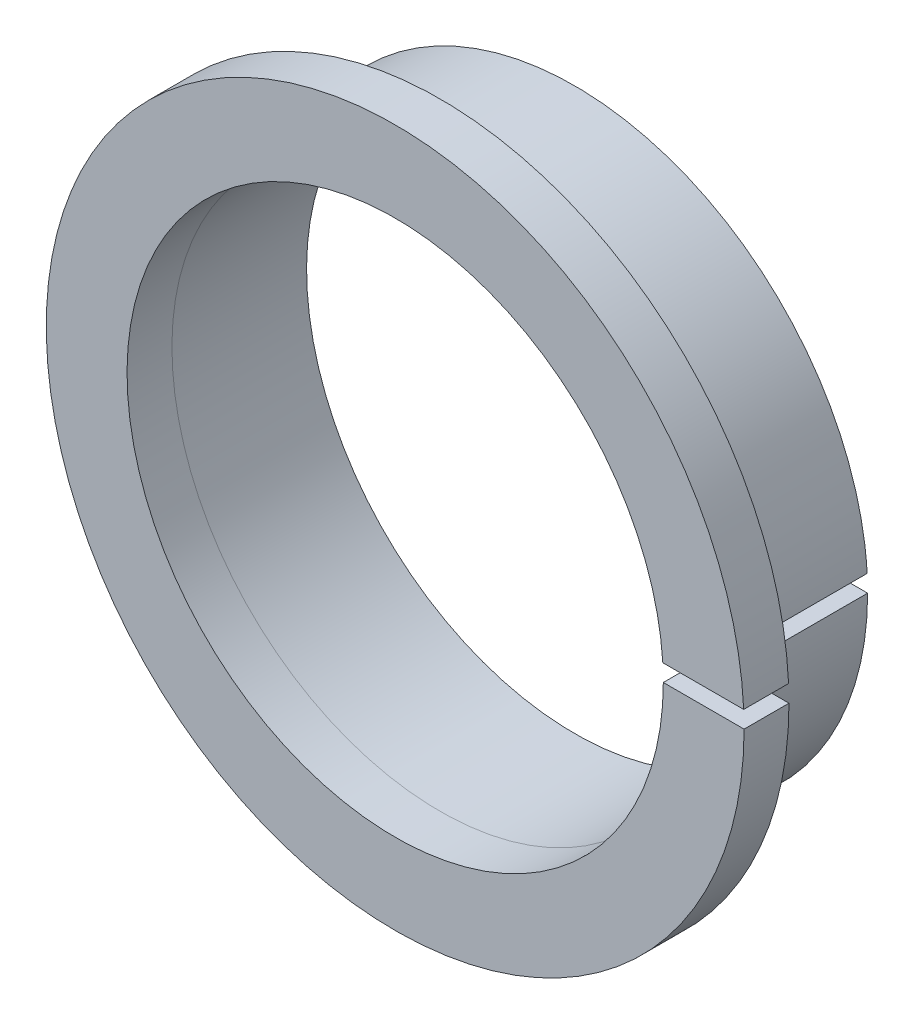
from build123d import *

# Parameters (mm, degrees)
BOSS_EXTRUDE1_DEPTH = 2
BOSS_EXTRUDE2_DEPTH = 6


with BuildPart() as part:
    # Sketch1 → Boss-Extrude1 (new body)
    with BuildSketch(Plane.XY):
        with BuildLine():
            Line((11.925831049, 0.750033398), (15.531084626, 0.75006687))
            ThreePointArc((15.531084626, 0.75006687), (-15.544679762, -0.375143285), (15.549186156, 0))
            Line((15.549186156, 0), (11.949393131, 0))
            ThreePointArc((11.949393131, 0), (-11.943497146, -0.375201418), (11.925831049, 0.750033398))
        make_face()
    extrude(amount=-BOSS_EXTRUDE1_DEPTH)

    # Sketch2 → Boss-Extrude2 (add)
    with BuildSketch(Plane(origin=(0, 0, -2), x_dir=(-1, 0, 0), z_dir=(0, 0, -1))):
        with BuildLine():
            Line((-13.054330915, 0), (-11.949393137, 0))
            ThreePointArc((-11.949393137, 0), (11.943513249, -0.375202113), (-11.925831049, 0.750033398))
            Line((-11.925831049, 0.750033398), (-13.032764674, 0.75006703))
            add(Edge.make_bspline(
                [(-13.054330915, 0), (-13.054331263, -22.118607412), (6.309344172, -11.428384425), (25.673019606, -0.738161438), (6.955565434, 11.046986129), (-11.761888738, 22.832133695), (-13.032764674, 0.75006703)],
                knots=[1.570796311, 1.570796311, 1.570796311, 3.646028424, 3.646028424, 5.721260538, 5.721260538, 7.796492651, 7.796492651, 7.796492651], degree=2, weights=[1, 0.50827474, 1, 0.50827474, 1, 0.50827474, 1]))
        make_face()
    extrude(amount=BOSS_EXTRUDE2_DEPTH)


solid = part.part
